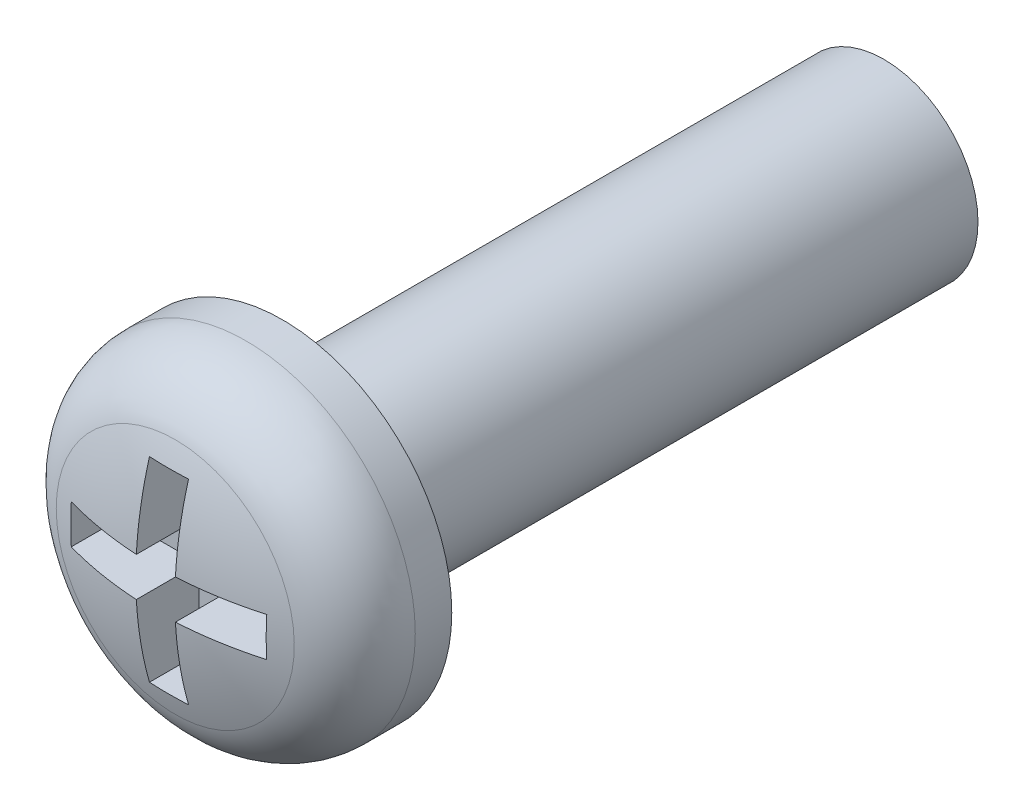
from build123d import *

# Parameters (mm, degrees)
CUT_EXTRUDE2_DEPTH = 0.85
FILLET1_R          = 1
CHAMFER1_SIZE      = 0.225
ESQUISSE1_R        = 1.25
BOSS_EXTRU_1_DEPTH = 8


with BuildPart() as part:
    # Sketch1 → Revolve1 (revolve)
    with BuildSketch(Plane(origin=(0, 0, 0), x_dir=(0, 0, -1), z_dir=(1, 0, 0))):
        with BuildLine():
            Line((-1.133333333, 2.25), (0, 2.25))
            Line((0, 2.25), (0, 1.25))
            Line((0, 1.25), (4, 1.25))
            Line((4, 1.25), (4, 0))
            Line((4, 0), (-1.7, 0))
            ThreePointArc((-1.7, 0), (-1.556155418, 1.1601305), (-1.133333333, 2.25))
        make_face()
    revolve(axis=Axis((0, 0, 33.735969773), (0, 0, -1)))

    # Sketch2 → Cut-Extrude2 (cut)
    with BuildSketch(Plane(origin=(0, 0, 1.7), x_dir=(-1, 0, 0), z_dir=(0, 0, -1))):
        Polygon((0, 1.3), (0.26, 1.3), (0.26, 0.26), (1.3, 0.26), (1.3, 0), (1.3, -0.26), (0.26, -0.26), (0.26, -1.3), (0, -1.3), (-0.26, -1.3), (-0.26, -0.26), (-1.3, -0.26), (-1.3, 0), (-1.3, 0.26), (-0.26, 0.26), (-0.26, 1.3), align=None)
    extrude(amount=CUT_EXTRUDE2_DEPTH, mode=Mode.SUBTRACT)

    # Fillet1
    fillet1_edges = [part.edges().sort_by_distance(p)[0] for p in [
        (0, -2.25, 1.133333333),
    ]]
    fillet(fillet1_edges, radius=FILLET1_R)

    # Chamfer1
    chamfer1_edges = [part.edges().sort_by_distance(p)[0] for p in [
        (0, -1.25, -4),
    ]]
    chamfer(chamfer1_edges, length=CHAMFER1_SIZE)

    # Esquisse1 → Boss.-Extru.1 (add)
    with BuildSketch(Plane(origin=(0, 0, 0), x_dir=(-1, 0, 0), z_dir=(0, 0, -1))):
        Circle(ESQUISSE1_R)
    extrude(amount=BOSS_EXTRU_1_DEPTH)


solid = part.part
